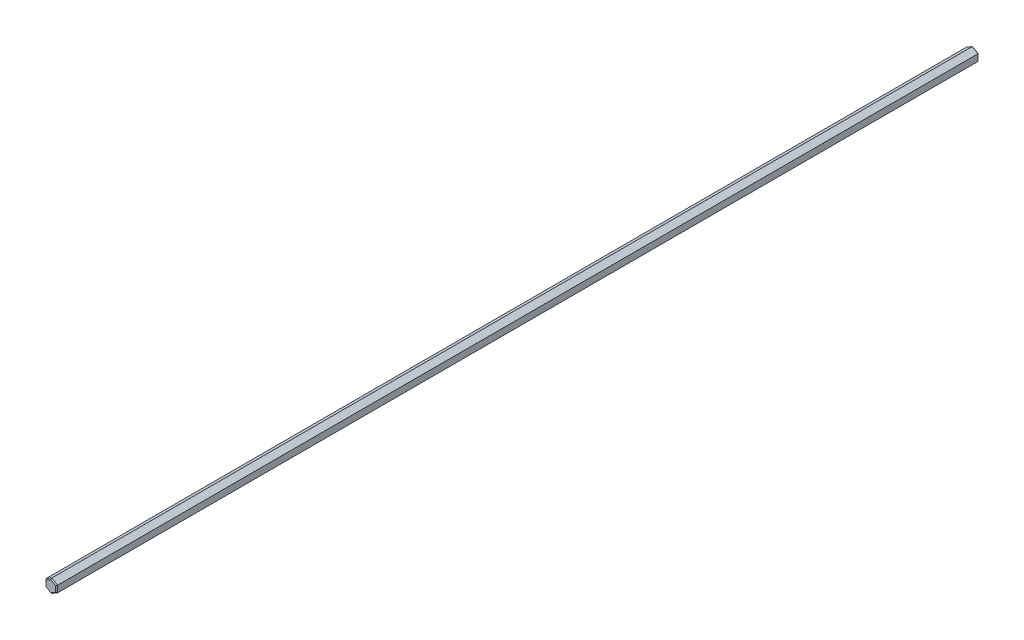
from build123d import *

# Parameters (mm, degrees)
BOSS_EXTRUDE1_DEPTH = 400
CHAMFER1_SIZE       = 0.4


with BuildPart() as part:
    # Sketch1 → Boss-Extrude1 (new body)
    with BuildSketch(Plane.XY.offset(400)):
        Polygon((0, -2.886751346), (2.5, -1.443375673), (2.5, 1.443375673), (0, 2.886751346), (-2.5, 1.443375673), (-2.5, -1.443375673), align=None)
    extrude(amount=-BOSS_EXTRUDE1_DEPTH)

    # Chamfer1
    chamfer1_edges = [part.edges().sort_by_distance(p)[0] for p in [
        (2.5, 0, 0),
        (1.25, 2.165063509, 0),
        (-1.25, 2.165063509, 0),
        (-2.5, 0, 0),
        (-1.25, -2.165063509, 0),
        (-2.5, 0, 400),
        (-1.25, 2.165063509, 400),
        (1.25, 2.165063509, 400),
        (1.25, -2.165063509, 0),
        (2.5, 0, 400),
        (1.25, -2.165063509, 400),
        (-1.25, -2.165063509, 400),
    ]]
    chamfer(chamfer1_edges, length=CHAMFER1_SIZE)


solid = part.part
